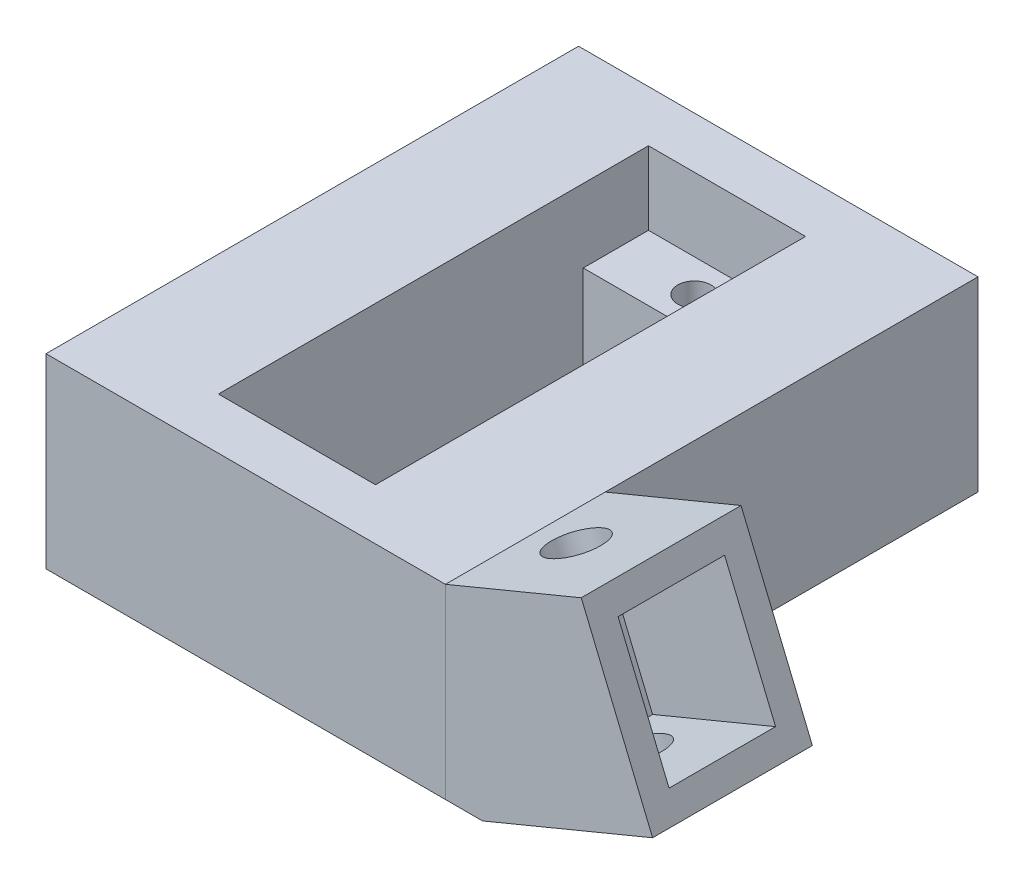
from build123d import *

# Parameters (mm, degrees)
BOSS_EXTRUDE1_DEPTH = 40
SKETCH4_W           = 11.8
SKETCH4_H           = 32.3
CUT_EXTRUDE1_DEPTH  = 5.5
SKETCH5_W           = 11.8
SKETCH5_H           = 22.5
CUT_EXTRUDE2_DEPTH  = 9.498848241
SKETCH6_R           = 1.25
CUT_EXTRUDE3_DEPTH  = 9.498848241
BOSS_EXTRUDE2_DEPTH = 12
SKETCH8_R           = 2
CUT_EXTRUDE4_DEPTH  = 30.384991323
SKETCH9_W           = 8
SKETCH9_H           = 10
CUT_EXTRUDE5_DEPTH  = 10


with BuildPart() as part:
    # Sketch1 → Boss-Extrude1 (new body)
    with BuildSketch(Plane.XY):
        Polygon((8.670952565, 9.003587153), (-11.329047435, 9.003587153), (-21.329047435, 9.003587153), (-21.329047435, -4.995261088), (-11.329047435, -4.995261088), (8.670952565, -4.995261088), align=None)
    extrude(amount=BOSS_EXTRUDE1_DEPTH)

    # Sketch4 → Cut-Extrude1 (cut)
    with BuildSketch(Plane(origin=(0, 9.003587153, 0), x_dir=(1, 0, 0), z_dir=(0, 1, 0))):
        with Locations((-6.329047435, -20)):
            Rectangle(SKETCH4_W, SKETCH4_H)
    extrude(amount=-CUT_EXTRUDE1_DEPTH, mode=Mode.SUBTRACT)

    # Sketch5 → Cut-Extrude2 (cut, through all)
    with BuildSketch(Plane(origin=(0, 3.503587153, 0), x_dir=(1, 0, 0), z_dir=(0, 1, 0))):
        with Locations((-6.329047435, -20)):
            Rectangle(SKETCH5_W, SKETCH5_H)
    extrude(amount=-CUT_EXTRUDE2_DEPTH, mode=Mode.SUBTRACT)

    # Sketch6 → Cut-Extrude3 (cut, through all)
    with BuildSketch(Plane(origin=(0, 3.503587153, 0), x_dir=(1, 0, 0), z_dir=(0, 1, 0))):
        with Locations((-6.329047435, -6.3)):
            Circle(SKETCH6_R)
        with Locations((-6.329047435, -33.7)):
            Circle(SKETCH6_R)
    extrude(amount=-CUT_EXTRUDE3_DEPTH, mode=Mode.SUBTRACT)


with BuildPart() as body_2:
    # Sketch7 → Boss-Extrude2 (new body)
    with BuildSketch(Plane.XY.offset(40)):
        Polygon((20.787289482, 8.610377228), (18.87387232, 13.229774891), (8.670952565, 9.003587153), (8.670952565, -4.995261088), (11.458506302, -4.995261088), (24.231440373, 0.295461436), align=None)
    extrude(amount=-BOSS_EXTRUDE2_DEPTH)

    # Sketch8 → Cut-Extrude4 (cut, through all)
    with BuildSketch(Plane(origin=(3.444150891, -8.314915793, 0), x_dir=(0.923879533, 0.382683432, 0), z_dir=(0.382683432, -0.923879533, 0))):
        with Locations((15.587337893, 34)):
            Circle(SKETCH8_R)
    extrude(amount=-CUT_EXTRUDE4_DEPTH, mode=Mode.SUBTRACT)

    # Sketch9 → Cut-Extrude5 (cut)
    with BuildSketch(Plane(origin=(20.787289482, 8.610377228, 0), x_dir=(0, 0, -1), z_dir=(0.923879533, 0.382683432, 0))):
        with Locations((-34, -2)):
            Rectangle(SKETCH9_W, SKETCH9_H)
    extrude(amount=-CUT_EXTRUDE5_DEPTH, mode=Mode.SUBTRACT)


solid = Compound([part.part, body_2.part])
